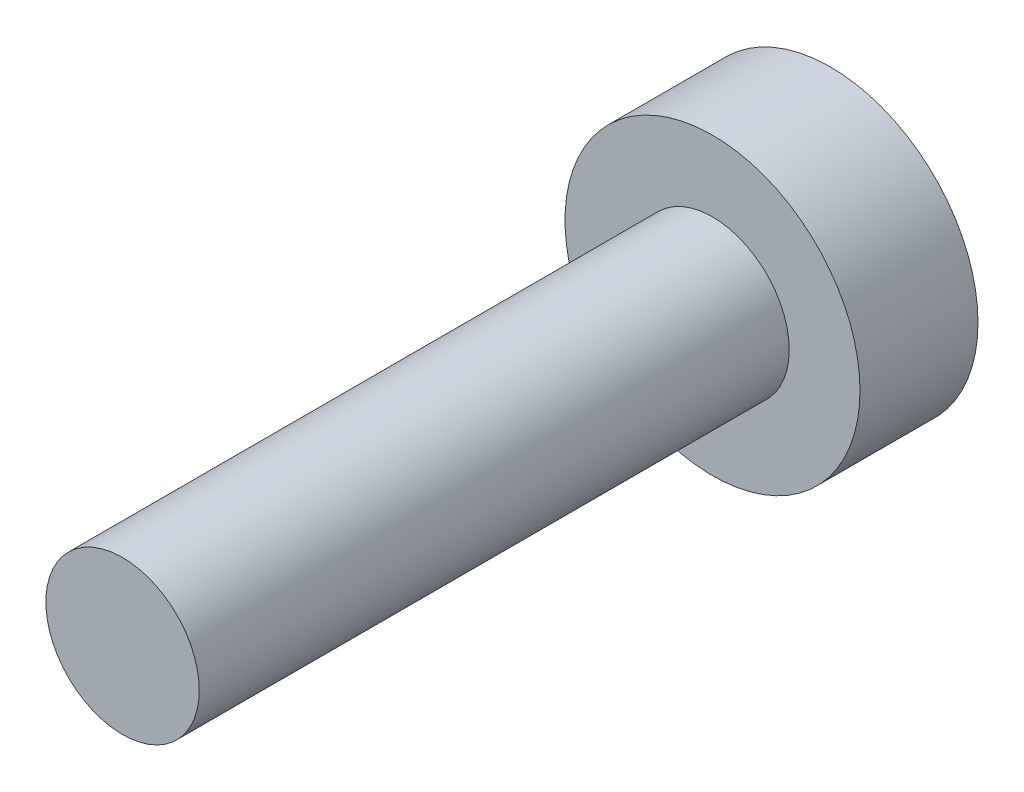
from build123d import *

# Parameters (mm, degrees)
SKETCH1_R           = 1.3
BOSS_EXTRUDE1_DEPTH = 10
SKETCH2_R           = 2.5
BOSS_EXTRUDE2_DEPTH = 2


with BuildPart() as part:
    # Sketch1 → Boss-Extrude1 (new body)
    with BuildSketch(Plane.XY):
        Circle(SKETCH1_R)
    extrude(amount=BOSS_EXTRUDE1_DEPTH)

    # Sketch2 → Boss-Extrude2 (add)
    with BuildSketch(Plane.XY):
        Circle(SKETCH2_R)
    extrude(amount=-BOSS_EXTRUDE2_DEPTH)


solid = part.part
